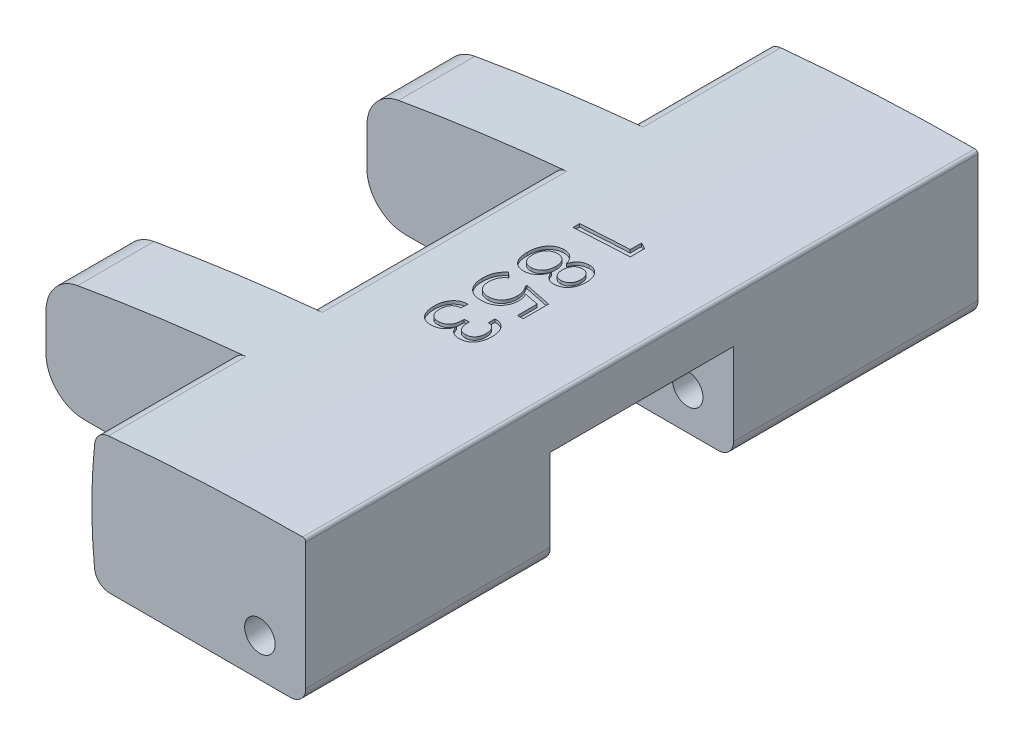
from build123d import *

# Parameters (mm, degrees)
SKETCH1_W               = 13
SKETCH1_H               = 4.75
BOSS_EXTRUDE1_DEPTH     = 22
CUT_EXTRUDE1_DEPTH      = 22
CUT_EXTRUDE2_DEPTH      = 4.5
CUT_EXTRUDE3_START      = -22
CUT_EXTRUDE3_DEPTH      = 4.5
FILLET1_R               = 0.5
FILLET2_R               = 0.5
FILLET3_R               = 0.1
SKETCH4_R               = 0.5
CUT_EXTRUDE4_DEPTH      = 24.5
FILLET4_R               = 1.25
SKETCH5_R               = 0.5
CUT_EXTRUDE5_DEPTH      = 24.5
CUT_EXTRUDE6_START      = -2.5
CUT_EXTRUDE6_DEPTH      = 8
CUT_EXTRUDE7_START      = -8
CUT_EXTRUDE7_DEPTH      = 6
CUT_EXTRUDE8_REACH      = 35.104
CUT_EXTRUDE8_END_RADIUS = 69.9
CUT_EXTRUDE8_START      = 10


with BuildPart() as part:
    # Sketch1 → Boss-Extrude1 (new body)
    with BuildSketch(Plane.XY):
        with Locations((0, 0.375)):
            Rectangle(SKETCH1_W, SKETCH1_H)
    extrude(amount=BOSS_EXTRUDE1_DEPTH)

    # Sketch2 → Cut-Extrude1 (cut)
    with BuildSketch(Plane.XY.offset(22)):
        with BuildLine():
            Line((-6.5, 1.5), (-7.817617934, 1.5))
            Line((-7.817617934, 1.5), (-7.817617934, 4.162106124))
            Line((-7.817617934, 4.162106124), (6.815359224, 3.9473364))
            Line((6.815359224, 3.9473364), (6.5, 2.75))
            ThreePointArc((6.5, 2.75), (-0.02921539, 2.428840055), (-6.5, 1.5))
        make_face()
    extrude(amount=-CUT_EXTRUDE1_DEPTH, mode=Mode.SUBTRACT)

    # Sketch3 → Cut-Extrude2 (cut)
    with BuildSketch(Plane.XY.offset(22)):
        with BuildLine():
            Line((-8.719422735, 4.296297838), (-0.5, 4.296297838))
            Line((-0.5, 4.296297838), (-0.359510145, 2.3962905))
            ThreePointArc((-0.359510145, 2.3962905), (-0.5, 0.19814525), (-0.359510145, -2))
            Line((-0.359510145, -2), (-0.5, -4.890115807))
            Line((-0.5, -4.890115807), (-8.719422735, -4.890115807))
            Line((-8.719422735, -4.890115807), (-8.719422735, 4.296297838))
        make_face()
    extrude(amount=-CUT_EXTRUDE2_DEPTH, mode=Mode.SUBTRACT)

    # Sketch3_2 → Cut-Extrude3 (cut)
    with BuildSketch(Plane.XY.offset(22).offset(CUT_EXTRUDE3_START)):
        with BuildLine():
            Line((-8.719422735, 4.296297838), (-0.5, 4.296297838))
            Line((-0.5, 4.296297838), (-0.359510145, 2.3962905))
            ThreePointArc((-0.359510145, 2.3962905), (-0.5, 0.19814525), (-0.359510145, -2))
            Line((-0.359510145, -2), (-0.5, -4.890115807))
            Line((-0.5, -4.890115807), (-8.719422735, -4.890115807))
            Line((-8.719422735, -4.890115807), (-8.719422735, 4.296297838))
        make_face()
    extrude(amount=CUT_EXTRUDE3_DEPTH, mode=Mode.SUBTRACT)

    # Fillet1
    fillet1_edges = [part.edges().sort_by_distance(p)[0] for p in [
        (-0.359510145, 2.3962905, 19.75),
        (-0.359510145, -2, 19.75),
        (-0.359510145, -2, 2.25),
        (-0.359510145, 2.3962905, 2.25),
    ]]
    fillet(fillet1_edges, radius=FILLET1_R)

    # Fillet2
    fillet2_edges = [part.edges().sort_by_distance(p)[0] for p in [
        (6.5, -2, 11),
    ]]
    fillet(fillet2_edges, radius=FILLET2_R)

    # Fillet3
    fillet3_edges = [part.edges().sort_by_distance(p)[0] for p in [
        (6.5, 2.75, 11),
    ]]
    fillet(fillet3_edges, radius=FILLET3_R)

    # Sketch4 → Cut-Extrude4 (cut)
    with BuildSketch(Plane.XY.offset(22)):
        with Locations((5, -0.75)):
            Circle(SKETCH4_R)
    extrude(amount=-CUT_EXTRUDE4_DEPTH, mode=Mode.SUBTRACT)

    # Fillet4
    fillet4_edges = [part.edges().sort_by_distance(p)[0] for p in [
        (-6.5, -2, 11),
        (-6.5, 1.5, 11),
    ]]
    fillet(fillet4_edges, radius=FILLET4_R)

    # Sketch5 → Cut-Extrude5 (cut)
    with BuildSketch(Plane.XY.offset(17.5)):
        with Locations((-2, -0.5)):
            Circle(SKETCH5_R)
    extrude(amount=-CUT_EXTRUDE5_DEPTH, mode=Mode.SUBTRACT)

    # Sketch6 → Cut-Extrude6 (cut)
    with BuildSketch(Plane.XY.offset(17.5).offset(CUT_EXTRUDE6_START)):
        with BuildLine():
            Line((-6.5, 0.458852446), (-6.5, -0.75))
            ThreePointArc((-6.5, -0.75), (-6.133883476, -1.633883476), (-5.25, -2))
            Line((-5.25, -2), (0.086216674, -2))
            ThreePointArc((0.086216674, -2), (-0.24895472, -1.87102579), (-0.41121225, -1.550640547))
            ThreePointArc((-0.41121225, -1.550640547), (-0.499986496, 0.219740337), (-0.406784166, 1.989893626))
            ThreePointArc((-0.406784166, 1.989893626), (-0.261418114, 2.293173746), (0.04317742, 2.435762952))
            ThreePointArc((0.04317742, 2.435762952), (-2.719189177, 2.117569669), (-5.466739147, 1.689918708))
            ThreePointArc((-5.466739147, 1.689918708), (-6.207450765, 1.262461824), (-6.5, 0.458852446))
        make_face()
    extrude(amount=-CUT_EXTRUDE6_DEPTH, mode=Mode.SUBTRACT)

    # Sketch7 → Cut-Extrude7 (cut)
    with BuildSketch(Plane.XY.offset(22).offset(CUT_EXTRUDE7_START)):
        with BuildLine():
            Line((0, -1.994783933), (-0.114543853, -3.669987776))
            Line((-0.114543853, -3.669987776), (10.452126541, -3.397946126))
            Line((10.452126541, -3.397946126), (6.5, 1.198125955))
            ThreePointArc((6.5, 1.198125955), (2.867210679, 0.380938411), (0, -1.994783933))
        make_face()
    extrude(amount=-CUT_EXTRUDE7_DEPTH, mode=Mode.SUBTRACT)

    # Cut-Extrude8: up to this cylinder (the profile starts outside it)
    cut_extrude8_end = Plane(origin=(6.670653075, -67.249791982, 10.8798785), z_dir=(0, 0, 1)) * Cylinder(CUT_EXTRUDE8_END_RADIUS, 215.772955, mode=Mode.PRIVATE)
    # Sketch10 → Cut-Extrude8 (cut, up to the surface)
    with BuildSketch(Plane(origin=(0, 0, 0), x_dir=(1, 0, 0), z_dir=(0, 1, 0)).offset(CUT_EXTRUDE8_START), mode=Mode.PRIVATE) as cut_extrude8_sk1:
        Polygon((1.887883315, -8.425655463), (3.54478633, -8.425655463), (3.54478633, -8.053309152), (3.764082317, -8.177043867), (3.764082317, -8.644951451), (1.887883315, -8.644951451), align=None)
    cut_extrude8_tool1 = extrude(cut_extrude8_sk1.sketch, amount=-CUT_EXTRUDE8_REACH, mode=Mode.PRIVATE) - cut_extrude8_end
    add(cut_extrude8_tool1.solids().sort_by_distance((2.942578, 10, 8.497401))[0], mode=Mode.SUBTRACT)
    # Sketch10 → Cut-Extrude8 (cut, up to the surface)
    with BuildSketch(Plane(origin=(0, 0, 0), x_dir=(1, 0, 0), z_dir=(0, 1, 0)).offset(CUT_EXTRUDE8_START), mode=Mode.PRIVATE) as cut_extrude8_sk2:
        with BuildLine():
            add(Edge.make_bspline(
                [(2.865577925, -9.83889627), (2.869838389, -9.826137367), (2.878206856, -9.801076139), (2.893577252, -9.765432704), (2.910213191, -9.731875229), (2.929424335, -9.701162211), (2.949859797, -9.672535013), (2.972122631, -9.646266572), (2.996450638, -9.622802745), (3.022560997, -9.601640223), (3.050491274, -9.582966099), (3.080201963, -9.566434341), (3.111961914, -9.552964653), (3.145142151, -9.541153276), (3.180495096, -9.533211466), (3.217407185, -9.526492152), (3.25624662, -9.522702862), (3.28271502, -9.52232669), (3.296174733, -9.522135399)],
                knots=[0, 0, 0, 0, 1.115070159, 2.190237476, 3.216326589, 4.218163628, 5.190828832, 6.131478805, 7.069298329, 7.989771955, 8.915106479, 9.852512516, 10.804690994, 11.773247773, 12.768818244, 13.805272428, 14.883936902, 16, 16, 16, 16], degree=3))
            add(Edge.make_bspline(
                [(3.296174733, -9.522135399), (3.312961584, -9.522475639), (3.34583066, -9.523141837), (3.393880454, -9.531297805), (3.439788918, -9.543253931), (3.483430477, -9.560424097), (3.524397605, -9.582823355), (3.563344221, -9.609707361), (3.599741086, -9.641763115), (3.633645133, -9.678394413), (3.664212625, -9.718845093), (3.691029472, -9.762435109), (3.71352065, -9.808921627), (3.732414637, -9.85810703), (3.746266793, -9.910641745), (3.756415171, -9.965878926), (3.763253847, -10.023884258), (3.763802567, -10.063502368), (3.764082317, -10.083700644)],
                knots=[0, 0, 0, 0, 0.9830839, 1.924902976, 2.84889234, 3.76073076, 4.66623393, 5.580497295, 6.529546941, 7.503495148, 8.501942846, 9.497225533, 10.498772977, 11.525428491, 12.581216274, 13.678548228, 14.816467425, 16, 16, 16, 16], degree=3))
            add(Edge.make_bspline(
                [(3.764082317, -10.083700644), (3.763813813, -10.104661284), (3.763290064, -10.145547432), (3.756391366, -10.20518583), (3.746493695, -10.261540386), (3.731907217, -10.31454983), (3.713231857, -10.364090443), (3.690753159, -10.410691905), (3.663707577, -10.453644993), (3.632724251, -10.492976013), (3.598684567, -10.528366237), (3.561385, -10.559155126), (3.521384061, -10.585063068), (3.478589844, -10.606265346), (3.433084686, -10.622609502), (3.384726813, -10.63437049), (3.333717222, -10.641822709), (3.298738968, -10.642590823), (3.280945845, -10.642981556)],
                knots=[0, 0, 0, 0, 1.206310217, 2.353047341, 3.452424765, 4.498409956, 5.513642797, 6.497379366, 7.472610848, 8.430159613, 9.375896207, 10.294710945, 11.20886428, 12.114124319, 13.03876164, 13.986979451, 14.975994558, 16, 16, 16, 16], degree=3))
            add(Edge.make_bspline(
                [(3.280945845, -10.642981556), (3.268498313, -10.642801162), (3.244049562, -10.642446842), (3.208029708, -10.638489135), (3.173369646, -10.632143543), (3.140201128, -10.622873858), (3.10839363, -10.611555572), (3.078106079, -10.597307941), (3.049268244, -10.580522445), (3.021645092, -10.561593128), (2.996171516, -10.539613752), (2.972213523, -10.515827775), (2.950317637, -10.489683973), (2.930573017, -10.46126789), (2.912095729, -10.430942442), (2.896351691, -10.397844435), (2.881623555, -10.363055242), (2.874005024, -10.338604069), (2.870146592, -10.326220686)],
                knots=[0, 0, 0, 0, 1.064786094, 2.091393704, 3.096757659, 4.076875836, 5.035335303, 5.982717519, 6.93642768, 7.888404947, 8.84372141, 9.811304894, 10.774918726, 11.757140486, 12.770333859, 13.80972889, 14.890729399, 16, 16, 16, 16], degree=3))
            add(Edge.make_bspline(
                [(2.870146592, -10.326220686), (2.865691978, -10.341277604), (2.856936283, -10.370872493), (2.839862454, -10.413224793), (2.820957135, -10.453240512), (2.79964935, -10.490804598), (2.775550368, -10.525464608), (2.749259119, -10.557619053), (2.720450554, -10.586994736), (2.689783771, -10.614211261), (2.656621786, -10.637866913), (2.622270846, -10.659256021), (2.585882913, -10.67658489), (2.548156383, -10.69125242), (2.508706303, -10.702197826), (2.467847714, -10.710146884), (2.425469515, -10.715341031), (2.396670447, -10.715831437), (2.382060731, -10.716080219)],
                knots=[0, 0, 0, 0, 1.11523967, 2.192041885, 3.240836628, 4.258740061, 5.256876497, 6.237213698, 7.206580286, 8.177958359, 9.146653525, 10.097853598, 11.049737434, 12.006053815, 12.971047805, 13.95440838, 14.962275052, 16, 16, 16, 16], degree=3))
            add(Edge.make_bspline(
                [(2.382060731, -10.716080219), (2.361608069, -10.715543824), (2.321572171, -10.714493835), (2.263075943, -10.707004095), (2.208017124, -10.693546599), (2.156327518, -10.675236586), (2.107772236, -10.652066581), (2.063127882, -10.622659854), (2.021285183, -10.58871917), (1.983256971, -10.549439133), (1.949377169, -10.505394837), (1.919382444, -10.457358717), (1.894932221, -10.404740037), (1.873932112, -10.348486615), (1.858804591, -10.287744215), (1.847308653, -10.223274544), (1.840363692, -10.154666048), (1.839563196, -10.107575474), (1.839150874, -10.083319922)],
                knots=[0, 0, 0, 0, 1.039943397, 2.035679615, 2.991992006, 3.916599957, 4.819975905, 5.720304265, 6.62839293, 7.554800695, 8.493200353, 9.44949097, 10.428036394, 11.438633929, 12.498253032, 13.605890068, 14.766834766, 16, 16, 16, 16], degree=3))
            add(Edge.make_bspline(
                [(1.839150874, -10.083319922), (1.839552201, -10.059568272), (1.840335158, -10.013230785), (1.847503031, -9.945709411), (1.858104361, -9.881798899), (1.874348245, -9.821911884), (1.894330188, -9.7655709), (1.919278216, -9.713267506), (1.948187301, -9.664397505), (1.982110224, -9.619986253), (2.019848874, -9.580046252), (2.060560209, -9.544520421), (2.105258786, -9.515284833), (2.15262946, -9.490464236), (2.203663947, -9.471964219), (2.257763338, -9.458613312), (2.315061481, -9.450489007), (2.354368159, -9.449527753), (2.374446287, -9.449036737)],
                knots=[0, 0, 0, 0, 1.216505243, 2.37330019, 3.475389416, 4.532104264, 5.548128315, 6.534081303, 7.496403654, 8.452224125, 9.390546075, 10.308069775, 11.213347525, 12.120654448, 13.042246906, 13.986855541, 14.971671587, 16, 16, 16, 16], degree=3))
            add(Edge.make_bspline(
                [(2.374446287, -9.449036737), (2.389311773, -9.449273786), (2.418620782, -9.449741155), (2.461702853, -9.455103391), (2.503414918, -9.462420042), (2.543461847, -9.473458361), (2.58171544, -9.488103079), (2.618396831, -9.505659762), (2.653481786, -9.526203258), (2.686727341, -9.549913243), (2.717895849, -9.576577175), (2.746936388, -9.605889109), (2.773284079, -9.638029384), (2.796970536, -9.672817629), (2.817984212, -9.710456434), (2.836513573, -9.750691917), (2.852711754, -9.793696763), (2.86122354, -9.823599095), (2.865577925, -9.83889627)],
                knots=[0, 0, 0, 0, 1.048540527, 2.067317862, 3.059891113, 4.035549704, 4.993702179, 5.947154508, 6.902624017, 7.859477869, 8.825136223, 9.794153254, 10.767795297, 11.754044294, 12.760582311, 13.806518336, 14.877877692, 16, 16, 16, 16], degree=3))
        make_face()
        with BuildLine():
            add(Edge.make_bspline(
                [(3.593518772, -10.083700644), (3.593381723, -10.070995516), (3.593113667, -10.046145338), (3.588614542, -10.009906), (3.582282332, -9.975659366), (3.573574155, -9.943188504), (3.561805674, -9.9128277), (3.547285441, -9.884556212), (3.530262874, -9.858336145), (3.511104729, -9.8340101), (3.489262851, -9.812471013), (3.465999206, -9.792995915), (3.440378884, -9.777147473), (3.4129369, -9.763994014), (3.383698876, -9.753785553), (3.352443866, -9.746470893), (3.319381138, -9.742381179), (3.296693195, -9.741751967), (3.28513379, -9.741431387)],
                knots=[0, 0, 0, 0, 1.170946256, 2.290273865, 3.362278628, 4.381619435, 5.385795872, 6.359427481, 7.307395176, 8.265210469, 9.208687803, 10.131836622, 11.057356673, 11.978723063, 12.933745364, 13.907517661, 14.933889642, 16, 16, 16, 16], degree=3))
            add(Edge.make_bspline(
                [(3.28513379, -9.741431387), (3.273696923, -9.74172625), (3.25150513, -9.742298394), (3.219155581, -9.746669491), (3.188582909, -9.753296328), (3.159912452, -9.76332636), (3.133099396, -9.775924866), (3.10805186, -9.791198384), (3.085213134, -9.809670712), (3.06411918, -9.830600029), (3.045619118, -9.854305303), (3.029093706, -9.880001963), (3.014912082, -9.907708194), (3.003967158, -9.937843065), (2.995215059, -9.969938022), (2.988738017, -10.004294459), (2.984906371, -10.040844872), (2.984547035, -10.065924317), (2.984363252, -10.078751256)],
                knots=[0, 0, 0, 0, 1.072122063, 2.080317407, 3.056176396, 4.000841677, 4.921822041, 5.830105027, 6.744526443, 7.670185174, 8.61064324, 9.558078038, 10.5320485, 11.522385724, 12.558842051, 13.648846602, 14.79749723, 16, 16, 16, 16], degree=3))
            add(Edge.make_bspline(
                [(2.984363252, -10.078751256), (2.984536192, -10.091960617), (2.984874527, -10.117803006), (2.988848382, -10.15531695), (2.994720857, -10.190644031), (3.00363999, -10.223576283), (3.01460716, -10.254429378), (3.027770884, -10.283196651), (3.044094664, -10.309366523), (3.062603693, -10.333344779), (3.083529284, -10.354581048), (3.106314769, -10.373184261), (3.131147765, -10.389010231), (3.158404897, -10.401180986), (3.187074415, -10.412021358), (3.218157445, -10.418433011), (3.250997352, -10.42280748), (3.27356931, -10.423388097), (3.28513379, -10.423685569)],
                knots=[0, 0, 0, 0, 1.219858798, 2.386494172, 3.481342231, 4.525089245, 5.533808128, 6.504186026, 7.441269036, 8.377030867, 9.297313476, 10.189072046, 11.090108438, 12.008072856, 12.942658737, 13.915512544, 14.932037126, 16, 16, 16, 16], degree=3))
            add(Edge.make_bspline(
                [(3.28513379, -10.423685569), (3.296698147, -10.423392575), (3.319143945, -10.422823888), (3.351862111, -10.418424048), (3.383008864, -10.411868724), (3.412065339, -10.401380872), (3.439645043, -10.388816451), (3.465114924, -10.373100467), (3.488979168, -10.354732138), (3.510698751, -10.333370404), (3.529927971, -10.309288167), (3.547302203, -10.283512104), (3.561342375, -10.255231975), (3.573260639, -10.22510002), (3.582323902, -10.192674033), (3.588628613, -10.158129099), (3.593113264, -10.121635851), (3.593381604, -10.096532665), (3.593518772, -10.083700644)],
                knots=[0, 0, 0, 0, 1.068935128, 2.074745862, 3.048485337, 4.006038069, 4.924838186, 5.846631144, 6.766779244, 7.70449509, 8.655698698, 9.612604022, 10.573028844, 11.568932583, 12.605424556, 13.680269707, 14.814221217, 16, 16, 16, 16], degree=3))
        make_face(mode=Mode.SUBTRACT)
        with BuildLine():
            add(Edge.make_bspline(
                [(2.009714419, -10.082558478), (2.009990334, -10.098180666), (2.010529942, -10.128733046), (2.015214078, -10.173266673), (2.022556448, -10.215386388), (2.033840197, -10.254627762), (2.047364734, -10.29165918), (2.06468118, -10.325795252), (2.084402893, -10.357852084), (2.107757897, -10.386662515), (2.133625165, -10.41277973), (2.162373923, -10.435229889), (2.193282341, -10.454519534), (2.226835078, -10.469624122), (2.262455511, -10.481994051), (2.3006101, -10.490720298), (2.341325623, -10.495564536), (2.369230449, -10.496369955), (2.38358362, -10.496784231)],
                knots=[0, 0, 0, 0, 1.185142581, 2.317788467, 3.394479188, 4.424957146, 5.412324218, 6.381345866, 7.324566267, 8.263055258, 9.189159501, 10.108126227, 11.024819467, 11.946959655, 12.894104844, 13.882269978, 14.910720986, 16, 16, 16, 16], degree=3))
            add(Edge.make_bspline(
                [(2.38358362, -10.496784231), (2.397935175, -10.496357396), (2.42608877, -10.495520068), (2.467198791, -10.490774533), (2.505945485, -10.481910217), (2.542143528, -10.469731231), (2.576211445, -10.454400117), (2.607794065, -10.435379866), (2.63696473, -10.41266062), (2.663603, -10.38671017), (2.687655544, -10.357861239), (2.708283405, -10.325937702), (2.725736361, -10.291566665), (2.740411513, -10.25480948), (2.751307667, -10.215318201), (2.759219603, -10.173296536), (2.764343457, -10.128751932), (2.764822451, -10.098182492), (2.765067264, -10.082558478)],
                knots=[0, 0, 0, 0, 1.080510182, 2.119647933, 3.109170154, 4.066776716, 4.990181468, 5.915807074, 6.83490296, 7.767159382, 8.710170064, 9.656079351, 10.621610152, 11.607899386, 12.630081868, 13.699855218, 14.824397965, 16, 16, 16, 16], degree=3))
            add(Edge.make_bspline(
                [(2.765067264, -10.082558478), (2.764825593, -10.067060616), (2.76435282, -10.036742797), (2.759172945, -9.99246244), (2.751375252, -9.950668074), (2.740333747, -9.911345281), (2.725746194, -9.874688561), (2.708275636, -9.840327869), (2.687676603, -9.808376369), (2.663469761, -9.779560026), (2.637114326, -9.753185358), (2.607675784, -9.730547803), (2.576237689, -9.711109847), (2.542229904, -9.695314093), (2.505935361, -9.683231636), (2.467201678, -9.674335323), (2.426087999, -9.669598783), (2.397934915, -9.6687602), (2.38358362, -9.668332724)],
                knots=[0, 0, 0, 0, 1.166972919, 2.282900211, 3.353516207, 4.367304737, 5.354370858, 6.320662195, 7.267316562, 8.211070041, 9.150747231, 10.070567076, 11.00189098, 11.930019938, 12.888380794, 13.878682449, 14.918638715, 16, 16, 16, 16], degree=3))
            add(Edge.make_bspline(
                [(2.38358362, -9.668332724), (2.369474611, -9.668532584), (2.341909864, -9.66892305), (2.301837289, -9.674667245), (2.263808746, -9.682650689), (2.228357407, -9.695137826), (2.194991024, -9.710176306), (2.164085373, -9.729162418), (2.135639096, -9.751698995), (2.109277252, -9.777259025), (2.085469486, -9.805783055), (2.065494756, -9.837619964), (2.048055254, -9.871818127), (2.034175256, -9.908780822), (2.023024569, -9.948376989), (2.015079815, -9.990661476), (2.010554305, -10.035756701), (2.009999283, -10.06668477), (2.009714419, -10.082558478)],
                knots=[0, 0, 0, 0, 1.069981757, 2.090421517, 3.06737467, 4.014815692, 4.937243903, 5.840971619, 6.760225376, 7.686719047, 8.624116241, 9.57278081, 10.533498568, 11.533592242, 12.564392062, 13.652647788, 14.795230821, 16, 16, 16, 16], degree=3))
        make_face(mode=Mode.SUBTRACT)
    cut_extrude8_tool2 = extrude(cut_extrude8_sk2.sketch, amount=-CUT_EXTRUDE8_REACH, mode=Mode.PRIVATE) - cut_extrude8_end
    add(cut_extrude8_tool2.solids().sort_by_distance((2.794139, 10, 10.08308))[0], mode=Mode.SUBTRACT)
    # Sketch10 → Cut-Extrude8 (cut, up to the surface)
    with BuildSketch(Plane(origin=(0, 0, 0), x_dir=(1, 0, 0), z_dir=(0, 1, 0)).offset(CUT_EXTRUDE8_START), mode=Mode.PRIVATE) as cut_extrude8_sk3:
        with BuildLine():
            Line((2.827124983, -11.137539694), (2.834739427, -11.093756641))
            Line((2.834739427, -11.093756641), (3.764082317, -11.317240573))
            Line((3.764082317, -11.317240573), (3.764082317, -12.143407747))
            Line((3.764082317, -12.143407747), (3.569152551, -12.143407747))
            Line((3.569152551, -12.143407747), (3.569152551, -11.495799284))
            Line((3.569152551, -11.495799284), (3.069645024, -11.375871791))
            add(Edge.make_bspline(
                [(3.069645024, -11.375871791), (3.076419646, -11.386556683), (3.089914082, -11.407840026), (3.106987407, -11.441519506), (3.121537127, -11.476422123), (3.137633742, -11.524381569), (3.151991838, -11.586627669), (3.153947167, -11.637466035), (3.154926797, -11.66293633)],
                knots=[0, 0, 0, 0, 0.749659619, 1.493254544, 2.235172988, 2.989349123, 4.49164773, 6, 6, 6, 6], degree=3))
            add(Edge.make_bspline(
                [(3.154926797, -11.66293633), (3.154406182, -11.684913452), (3.153388787, -11.727861568), (3.145705201, -11.790579188), (3.132924544, -11.849798025), (3.114474469, -11.905544231), (3.090897745, -11.957755434), (3.062157589, -12.0066103), (3.02800651, -12.051667089), (2.989162442, -12.093210486), (2.945902556, -12.130575454), (2.898167208, -12.162650081), (2.847050087, -12.190109984), (2.792275367, -12.212832295), (2.733572798, -12.229672923), (2.671366501, -12.242427428), (2.605325542, -12.249480137), (2.560127346, -12.250586418), (2.537014666, -12.251152129)],
                knots=[0, 0, 0, 0, 1.093405914, 2.136754893, 3.138867619, 4.103425186, 5.053065585, 5.984494365, 6.91786926, 7.860597268, 8.809964659, 9.755796845, 10.716439283, 11.693342276, 12.700476662, 13.75072131, 14.849802379, 16, 16, 16, 16], degree=3))
            add(Edge.make_bspline(
                [(2.537014666, -12.251152129), (2.510845254, -12.250572462), (2.459750894, -12.249440693), (2.385250944, -12.24047388), (2.314813349, -12.226275355), (2.248652611, -12.205596221), (2.186627289, -12.179275043), (2.128654173, -12.147207367), (2.075169463, -12.108831671), (2.025906564, -12.065040162), (1.981983494, -12.016042564), (1.943342124, -11.962749654), (1.911515576, -11.90471418), (1.884596945, -11.842894744), (1.864065523, -11.776616217), (1.849782465, -11.706076193), (1.840887271, -11.631436298), (1.839738037, -11.580218069), (1.839150874, -11.554049781)],
                knots=[0, 0, 0, 0, 1.125009158, 2.19651937, 3.22181462, 4.210814471, 5.171712849, 6.114654191, 7.053528485, 7.996611934, 8.94333552, 9.877774575, 10.820715917, 11.783765811, 12.772765662, 13.798060912, 14.874990842, 16, 16, 16, 16], degree=3))
            add(Edge.make_bspline(
                [(1.839150874, -11.554049781), (1.839898971, -11.522659138), (1.841347118, -11.461893918), (1.854038892, -11.37429486), (1.874765995, -11.293703841), (1.904234343, -11.219770569), (1.943462828, -11.152137249), (1.991776203, -11.08974616), (2.049767136, -11.032317515), (2.094289806, -10.999674386), (2.11707808, -10.982966481)],
                knots=[0, 0, 0, 0, 1.133977449, 2.19512516, 3.190766457, 4.135286887, 5.062000698, 6.006910794, 6.97986663, 8, 8, 8, 8], degree=3))
            Line((2.11707808, -10.982966481), (2.302109069, -11.145154138))
            add(Edge.make_bspline(
                [(2.302109069, -11.145154138), (2.2832393, -11.156193558), (2.246140878, -11.177897325), (2.196904435, -11.218913354), (2.154800605, -11.265716321), (2.11947529, -11.317751047), (2.091906911, -11.374841914), (2.072680051, -11.436305426), (2.060344042, -11.501779124), (2.059090401, -11.546885403), (2.058446861, -11.570040113)],
                knots=[0, 0, 0, 0, 1.015581037, 1.996656862, 2.966371388, 3.935654578, 4.91254783, 5.903888654, 6.923989037, 8, 8, 8, 8], degree=3))
            add(Edge.make_bspline(
                [(2.058446861, -11.570040113), (2.058765228, -11.586938048), (2.059387414, -11.619961713), (2.06563955, -11.668276892), (2.075873862, -11.714026711), (2.090001335, -11.757255409), (2.107881946, -11.798156564), (2.1306293, -11.836223369), (2.156912792, -11.872134814), (2.186945419, -11.90542646), (2.220832273, -11.934803147), (2.25726739, -11.961045109), (2.296474107, -11.983312222), (2.338778356, -12.000483466), (2.383189823, -12.015023926), (2.430599567, -12.024544258), (2.480618807, -12.030949014), (2.514911355, -12.031549234), (2.532446, -12.031856142)],
                knots=[0, 0, 0, 0, 1.086858341, 2.124049317, 3.128479452, 4.099455711, 5.04633589, 5.994482894, 6.946700422, 7.906347316, 8.872745664, 9.826782272, 10.792075928, 11.765726964, 12.76001445, 13.794630469, 14.872338945, 16, 16, 16, 16], degree=3))
            add(Edge.make_bspline(
                [(2.532446, -12.031856142), (2.548968788, -12.03157653), (2.581387441, -12.031027915), (2.62863457, -12.024193974), (2.673563201, -12.014067109), (2.716009378, -11.99964429), (2.755784741, -11.98068956), (2.7935375, -11.958367796), (2.828115355, -11.930891487), (2.860642807, -11.900172146), (2.889639471, -11.865745167), (2.915150833, -11.828427732), (2.936322309, -11.788355508), (2.954085576, -11.745708013), (2.967659595, -11.700261086), (2.977577551, -11.652254699), (2.983326709, -11.601526782), (2.984011681, -11.566882172), (2.984363252, -11.549100392)],
                knots=[0, 0, 0, 0, 1.063936886, 2.087504949, 3.069488103, 4.028976296, 4.969171371, 5.904659737, 6.848582027, 7.808801843, 8.783676018, 9.743164211, 10.716356118, 11.698986086, 12.715735968, 13.767883803, 14.854338392, 16, 16, 16, 16], degree=3))
            add(Edge.make_bspline(
                [(2.984363252, -11.549100392), (2.983998841, -11.530289271), (2.983274323, -11.492889118), (2.975174157, -11.437636569), (2.963120942, -11.383569808), (2.945912641, -11.330918361), (2.923721151, -11.279689472), (2.896586033, -11.230124901), (2.864618562, -11.182200463), (2.83972353, -11.152546551), (2.827124983, -11.137539694)],
                knots=[0, 0, 0, 0, 1.001435431, 1.991047666, 2.968576839, 3.949932885, 4.937117188, 5.938575441, 6.956781648, 8, 8, 8, 8], degree=3))
        make_face()
    cut_extrude8_tool3 = extrude(cut_extrude8_sk3.sketch, amount=-CUT_EXTRUDE8_REACH, mode=Mode.PRIVATE) - cut_extrude8_end
    add(cut_extrude8_tool3.solids().sort_by_distance((2.853643, 10, 11.119598))[0], mode=Mode.SUBTRACT)
    # Sketch10 → Cut-Extrude8 (cut, up to the surface)
    with BuildSketch(Plane(origin=(0, 0, 0), x_dir=(1, 0, 0), z_dir=(0, 1, 0)).offset(CUT_EXTRUDE8_START), mode=Mode.PRIVATE) as cut_extrude8_sk4:
        with BuildLine():
            Line((2.375207731, -12.567913), (2.36454751, -12.787208987))
            Line((2.36454751, -12.787208987), (2.342846344, -12.787208987))
            add(Edge.make_bspline(
                [(2.342846344, -12.787208987), (2.331405813, -12.787478298), (2.308938194, -12.788007188), (2.276225974, -12.792838882), (2.245055731, -12.799732823), (2.216101354, -12.81069268), (2.188582122, -12.823974423), (2.16320455, -12.840874847), (2.139321029, -12.860489717), (2.117303213, -12.882894579), (2.097565435, -12.907870381), (2.080621837, -12.935414054), (2.066234487, -12.965009741), (2.054439425, -12.996765861), (2.045158224, -13.030643084), (2.039032056, -13.066745446), (2.034462312, -13.104996773), (2.034210077, -13.13124009), (2.03408064, -13.144707133)],
                knots=[0, 0, 0, 0, 1.029050895, 2.020913481, 2.971259222, 3.896421156, 4.800613927, 5.716206796, 6.633223605, 7.578268764, 8.538041007, 9.49215485, 10.483227841, 11.495274799, 12.537178303, 13.639564971, 14.788717158, 16, 16, 16, 16], degree=3))
            add(Edge.make_bspline(
                [(2.03408064, -13.144707133), (2.0343396, -13.160077228), (2.034841624, -13.189874043), (2.039678, -13.233231793), (2.046648707, -13.27403296), (2.056944976, -13.31227952), (2.070229164, -13.347908701), (2.0867202, -13.380738782), (2.1057675, -13.411129927), (2.127903293, -13.438573559), (2.152797101, -13.463121814), (2.180257981, -13.48447506), (2.2102363, -13.502621083), (2.24283588, -13.516954028), (2.277763177, -13.528466794), (2.31511193, -13.536781584), (2.355016815, -13.541840703), (2.382426009, -13.542316851), (2.396528175, -13.542561832)],
                knots=[0, 0, 0, 0, 1.205260865, 2.336546016, 3.418436897, 4.44962557, 5.438873324, 6.396093775, 7.326856691, 8.247286696, 9.155413036, 10.063484806, 10.970081944, 11.897003566, 12.850905007, 13.850815321, 14.894233843, 16, 16, 16, 16], degree=3))
            add(Edge.make_bspline(
                [(2.396528175, -13.542561832), (2.411143845, -13.54234872), (2.439450164, -13.541935985), (2.480483465, -13.536487361), (2.519092693, -13.529554507), (2.554661473, -13.517545455), (2.588063987, -13.503934225), (2.618346301, -13.485947148), (2.646303348, -13.465575156), (2.671220132, -13.441626377), (2.693522483, -13.414735213), (2.712918458, -13.384744295), (2.728882534, -13.351500467), (2.742258923, -13.315718156), (2.752433958, -13.276787758), (2.760130089, -13.235075565), (2.764125473, -13.190217892), (2.764746889, -13.159435215), (2.765067264, -13.143564966)],
                knots=[0, 0, 0, 0, 1.129513816, 2.187541035, 3.198199858, 4.157401914, 5.08540908, 5.982747692, 6.874052983, 7.755793936, 8.64812561, 9.571135618, 10.510596911, 11.495178542, 12.52140034, 13.618853924, 14.772381534, 16, 16, 16, 16], degree=3))
            Line((2.765067264, -13.143564966), (2.765067264, -13.104731302))
            Line((2.765067264, -13.104731302), (2.765067264, -13.079603636))
            Line((2.765067264, -13.079603636), (2.936772977, -13.079603636))
            Line((2.936772977, -13.079603636), (2.93563081, -13.108157801))
            Line((2.93563081, -13.108157801), (2.93563081, -13.138234855))
            add(Edge.make_bspline(
                [(2.93563081, -13.138234855), (2.935810036, -13.153345093), (2.936158562, -13.182728769), (2.939992289, -13.225352725), (2.94638661, -13.265202351), (2.95548438, -13.302121738), (2.966977636, -13.336231399), (2.980514213, -13.367847677), (2.997387413, -13.396303296), (3.016418263, -13.422194742), (3.038458009, -13.444790906), (3.062698166, -13.464743329), (3.089814658, -13.481037092), (3.118833452, -13.495112944), (3.150850232, -13.505109649), (3.185086212, -13.512764153), (3.221809971, -13.517374503), (3.247048491, -13.517917059), (3.260006124, -13.518195611)],
                knots=[0, 0, 0, 0, 1.269850296, 2.469376785, 3.593533556, 4.659495338, 5.66140026, 6.616733268, 7.544325747, 8.436141459, 9.311276616, 10.190951223, 11.067320842, 11.964416439, 12.895498767, 13.879004877, 14.911066249, 16, 16, 16, 16], degree=3))
            add(Edge.make_bspline(
                [(3.260006124, -13.518195611), (3.271313275, -13.517881023), (3.29349846, -13.517263787), (3.326031852, -13.513062205), (3.356947084, -13.505919208), (3.386008672, -13.495557954), (3.413259802, -13.482458237), (3.438987041, -13.466918816), (3.462737544, -13.447958249), (3.484688697, -13.426397017), (3.504545741, -13.402251363), (3.522128855, -13.376102696), (3.536613858, -13.347651604), (3.548389088, -13.31725006), (3.558088317, -13.284974779), (3.564223141, -13.250343217), (3.568757609, -13.21386468), (3.569018957, -13.188759429), (3.569152551, -13.175926353)],
                knots=[0, 0, 0, 0, 1.042902441, 2.046225875, 3.020163831, 3.964309802, 4.885832935, 5.805346364, 6.730431526, 7.682382878, 8.638643025, 9.609410028, 10.583207272, 11.576648209, 12.613819107, 13.68600624, 14.817153566, 16, 16, 16, 16], degree=3))
            add(Edge.make_bspline(
                [(3.569152551, -13.175926353), (3.568948084, -13.162466058), (3.568550021, -13.13626115), (3.56502877, -13.097983392), (3.55945493, -13.061826674), (3.551373364, -13.027737489), (3.541333076, -12.99561058), (3.528158503, -12.965978907), (3.513434383, -12.938139388), (3.501564987, -12.9212373), (3.495673166, -12.912847313)],
                knots=[0, 0, 0, 0, 1.162137991, 2.262485277, 3.316505237, 4.318655975, 5.285613233, 6.218109823, 7.115491835, 8, 8, 8, 8], degree=3))
            add(Edge.make_bspline(
                [(3.495673166, -12.912847313), (3.489392594, -12.905055117), (3.476904289, -12.889561096), (3.454939188, -12.869644132), (3.431670667, -12.851664514), (3.406039406, -12.837374805), (3.378645726, -12.825697633), (3.349244188, -12.817380982), (3.317672958, -12.812290124), (3.295940862, -12.811818171), (3.284753067, -12.811575208)],
                knots=[0, 0, 0, 0, 0.986983087, 1.962519489, 2.920096456, 3.885515851, 4.851585907, 5.855298712, 6.895896706, 8, 8, 8, 8], degree=3))
            Line((3.284753067, -12.811575208), (3.285895234, -12.59227922))
            add(Edge.make_bspline(
                [(3.285895234, -12.59227922), (3.304321241, -12.592807032), (3.340320715, -12.593838235), (3.39259824, -12.601389887), (3.441483101, -12.614465207), (3.487194075, -12.632514923), (3.530107936, -12.655363485), (3.56996653, -12.683667744), (3.607521959, -12.716211894), (3.629584934, -12.741376313), (3.640728324, -12.754086155)],
                knots=[0, 0, 0, 0, 1.094993044, 2.139322676, 3.131004981, 4.096082529, 5.054475118, 6.012897389, 6.996370143, 8, 8, 8, 8], degree=3))
            add(Edge.make_bspline(
                [(3.640728324, -12.754086155), (3.650657421, -12.767216466), (3.670677116, -12.793690659), (3.695766139, -12.837417311), (3.716652795, -12.884742307), (3.734391183, -12.93545491), (3.747350549, -12.990252038), (3.757393931, -13.048454675), (3.763021117, -13.110331198), (3.763722712, -13.152691518), (3.764082317, -13.174403464)],
                knots=[0, 0, 0, 0, 0.884020027, 1.782419126, 2.701345473, 3.66114816, 4.665218348, 5.723662295, 6.833254264, 8, 8, 8, 8], degree=3))
            add(Edge.make_bspline(
                [(3.764082317, -13.174403464), (3.763810361, -13.195363404), (3.763279878, -13.236248185), (3.75644338, -13.295772118), (3.746387191, -13.352091502), (3.731923553, -13.405253144), (3.713205771, -13.455150632), (3.690889891, -13.502105621), (3.663466057, -13.545180783), (3.632867932, -13.58516386), (3.598649457, -13.621064161), (3.561006506, -13.652142768), (3.520459956, -13.678469836), (3.477254893, -13.700349917), (3.431134263, -13.717265077), (3.382163848, -13.728800463), (3.330422392, -13.736385471), (3.294933716, -13.73711696), (3.276757901, -13.737491598)],
                knots=[0, 0, 0, 0, 1.197123987, 2.335128539, 3.419000603, 4.464013975, 5.478304823, 6.46107359, 7.428878541, 8.390578094, 9.334337519, 10.256364722, 11.173588177, 12.091413476, 13.01830464, 13.973391855, 14.962056141, 16, 16, 16, 16], degree=3))
            add(Edge.make_bspline(
                [(3.276757901, -13.737491598), (3.263673798, -13.737342848), (3.237815478, -13.737048869), (3.199921105, -13.732609324), (3.163444848, -13.726089252), (3.128275388, -13.717612124), (3.0948019, -13.705563367), (3.062539857, -13.691459049), (3.031727303, -13.674825394), (3.00277513, -13.655300434), (2.975674642, -13.633504586), (2.950411146, -13.609689116), (2.928032089, -13.583065964), (2.907365921, -13.554942058), (2.888843011, -13.524583125), (2.873079835, -13.491845434), (2.85919612, -13.457142763), (2.852061543, -13.432978324), (2.848445426, -13.420730728)],
                knots=[0, 0, 0, 0, 1.088212303, 2.150651252, 3.169853536, 4.17133881, 5.156657359, 6.125999796, 7.099475418, 8.066052578, 9.027597407, 9.991169896, 10.949926959, 11.917369118, 12.893590475, 13.904331766, 14.937823518, 16, 16, 16, 16], degree=3))
            add(Edge.make_bspline(
                [(2.848445426, -13.420730728), (2.84584953, -13.433593047), (2.840735177, -13.458933979), (2.829755591, -13.495773731), (2.815148435, -13.530312113), (2.798086899, -13.562976634), (2.777640514, -13.593230707), (2.754440419, -13.621537805), (2.727870966, -13.647508468), (2.698734037, -13.671394088), (2.666972553, -13.692758722), (2.633029613, -13.711527824), (2.596776616, -13.727090773), (2.558502034, -13.739595559), (2.518291963, -13.749523454), (2.47593866, -13.756791568), (2.431382703, -13.760911662), (2.40097818, -13.761538466), (2.385487231, -13.761857819)],
                knots=[0, 0, 0, 0, 0.998301717, 1.966822134, 2.919222075, 3.848071724, 4.766824882, 5.693009679, 6.628612868, 7.589446685, 8.556425024, 9.537622636, 10.536904889, 11.553904406, 12.598591055, 13.686189128, 14.821125186, 16, 16, 16, 16], degree=3))
            add(Edge.make_bspline(
                [(2.385487231, -13.761857819), (2.364906135, -13.761329336), (2.324614385, -13.76029472), (2.26591531, -13.752711593), (2.210539245, -13.739716182), (2.15850179, -13.721491748), (2.109909803, -13.697706437), (2.064529836, -13.668911008), (2.022587386, -13.6349757), (1.984308028, -13.595851742), (1.950181386, -13.552124441), (1.92035267, -13.504256259), (1.895078414, -13.452468155), (1.874542148, -13.39657608), (1.858648891, -13.336652519), (1.847320765, -13.272726912), (1.840382357, -13.204887996), (1.839568163, -13.158303171), (1.839150874, -13.134427633)],
                knots=[0, 0, 0, 0, 1.04883822, 2.053317705, 3.01036005, 3.943227847, 4.857362316, 5.761741811, 6.676974065, 7.600919005, 8.545486407, 9.498520295, 10.470506316, 11.477398719, 12.528627638, 13.626120549, 14.783345272, 16, 16, 16, 16], degree=3))
            add(Edge.make_bspline(
                [(1.839150874, -13.134427633), (1.839635281, -13.113221154), (1.840577153, -13.071987704), (1.846566721, -13.011730038), (1.857288692, -12.954830394), (1.871987576, -12.90114474), (1.890973144, -12.850764036), (1.914942335, -12.804221622), (1.942208149, -12.760378246), (1.974250465, -12.720605758), (2.009659916, -12.684690776), (2.048170815, -12.653317888), (2.089740419, -12.626878761), (2.134010053, -12.604828373), (2.181679892, -12.5888319), (2.231781717, -12.576383141), (2.284889409, -12.569095579), (2.321250111, -12.568312507), (2.339800567, -12.567913)],
                knots=[0, 0, 0, 0, 1.192861821, 2.319376411, 3.401597025, 4.445886083, 5.446799128, 6.423674697, 7.386151978, 8.346005076, 9.289905902, 10.218568355, 11.133410654, 12.056017745, 12.992874436, 13.955484063, 14.956931505, 16, 16, 16, 16], degree=3))
            Line((2.339800567, -12.567913), (2.375207731, -12.567913))
        make_face()
    cut_extrude8_tool4 = extrude(cut_extrude8_sk4.sketch, amount=-CUT_EXTRUDE8_REACH, mode=Mode.PRIVATE) - cut_extrude8_end
    add(cut_extrude8_tool4.solids().sort_by_distance((2.794747, 10, 13.262356))[0], mode=Mode.SUBTRACT)


solid = part.part
